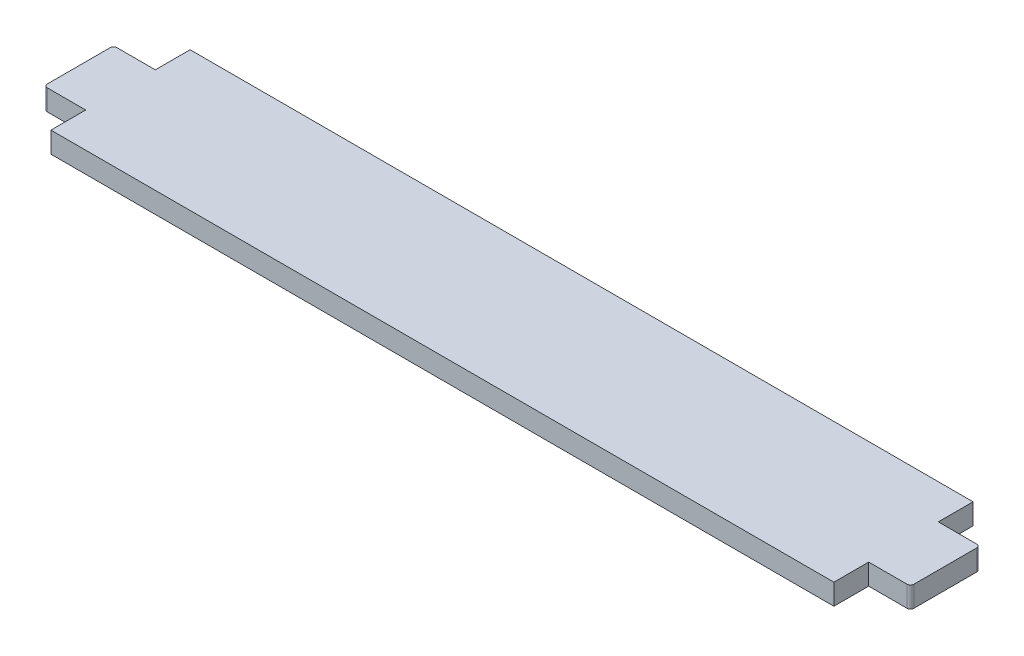
from build123d import *

# Parameters (mm, degrees)
SKETCH_1_W      = 6
SKETCH_1_H      = 10
SKETCH_1_W_2    = 112.5
SKETCH_1_H_2    = 20
EXTRUDE_1_DEPTH = 3
FILLET_1_R      = 0.5


with BuildPart() as part:
    # Эскиз1 → Бобышка-Вытянуть1 (new body)
    with BuildSketch(Plane(origin=(0, 0, 0), x_dir=(1, 0, 0), z_dir=(0, 1, 0))):
        with Locations((-59.25, 0)):
            Rectangle(SKETCH_1_W, SKETCH_1_H)
        Rectangle(SKETCH_1_W_2, SKETCH_1_H_2)
        with Locations((59.25, 0)):
            Rectangle(SKETCH_1_W, SKETCH_1_H)
    extrude(amount=EXTRUDE_1_DEPTH)

    # Скругление1
    fillet_1_edges = [part.edges().sort_by_distance(p)[0] for p in [
        (-62.25, 1.5, 5),
        (-62.25, 1.5, -5),
        (62.25, 1.5, -5),
        (62.25, 1.5, 5),
    ]]
    fillet(fillet_1_edges, radius=FILLET_1_R)


solid = part.part
